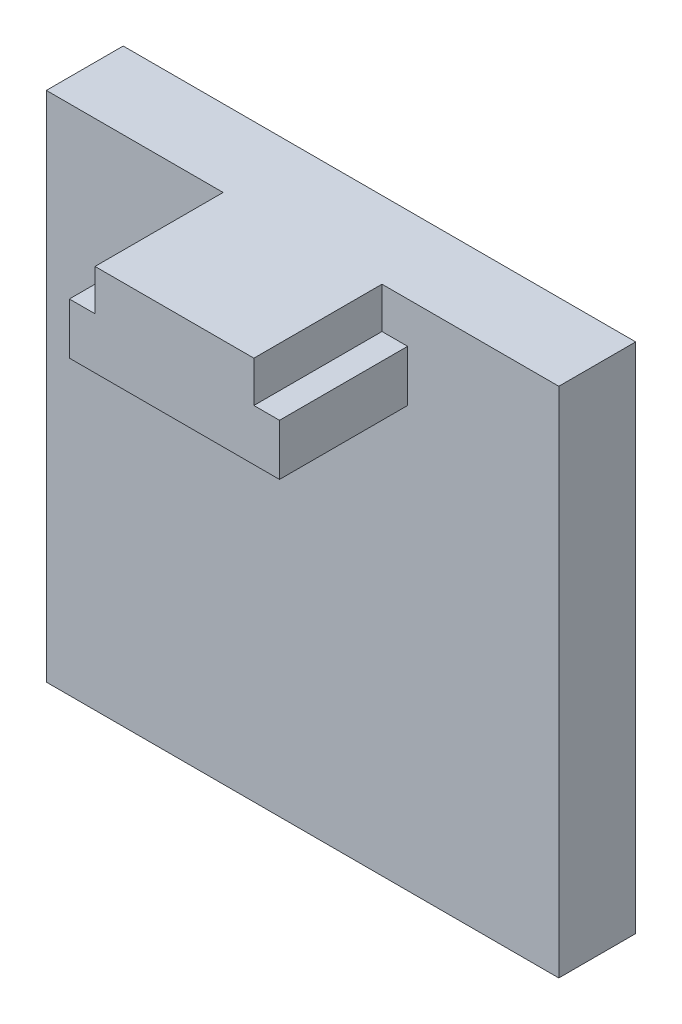
from build123d import *

# Parameters (mm, degrees)
SKETCH1_W           = 20
SKETCH1_H           = 20
BOSS_EXTRUDE1_DEPTH = 3
BOSS_EXTRUDE2_DEPTH = 5


with BuildPart() as part:
    # Sketch1 → Boss-Extrude1 (new body)
    with BuildSketch(Plane.XY):
        with Locations((10, 10)):
            Rectangle(SKETCH1_W, SKETCH1_H)
    extrude(amount=BOSS_EXTRUDE1_DEPTH)

    # Sketch2 → Boss-Extrude2 (add)
    with BuildSketch(Plane.XY.offset(3)):
        Polygon((6.9, 20), (6.9, 18.4), (5.9, 18.4), (5.9, 16.4), (13.1, 16.4), (14.1, 16.4), (14.1, 18.4), (13.1, 18.4), (13.1, 20), align=None)
    extrude(amount=BOSS_EXTRUDE2_DEPTH)


solid = part.part
